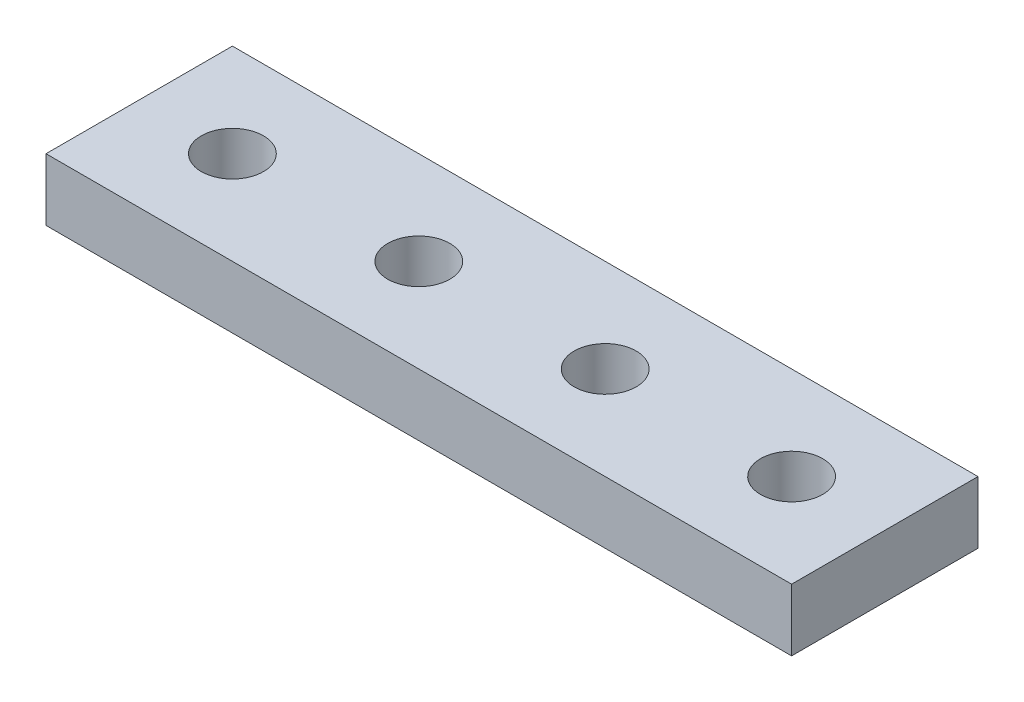
from build123d import *

# Parameters (mm, degrees)
SKETCH1_W           = 120
SKETCH1_H           = 30
SKETCH1_R           = 5
BOSS_EXTRUDE1_DEPTH = 10


with BuildPart() as part:
    # Sketch1 → Boss-Extrude1 (new body)
    with BuildSketch(Plane(origin=(0, 0, 0), x_dir=(1, 0, 0), z_dir=(0, 1, 0))):
        with Locations((60, 15)):
            Rectangle(SKETCH1_W, SKETCH1_H)
        with Locations((15, 15)):
            Circle(SKETCH1_R, mode=Mode.SUBTRACT)
        with Locations((45, 15)):
            Circle(SKETCH1_R, mode=Mode.SUBTRACT)
        with Locations((75, 15)):
            Circle(SKETCH1_R, mode=Mode.SUBTRACT)
        with Locations((105, 15)):
            Circle(SKETCH1_R, mode=Mode.SUBTRACT)
    extrude(amount=BOSS_EXTRUDE1_DEPTH)


solid = part.part
